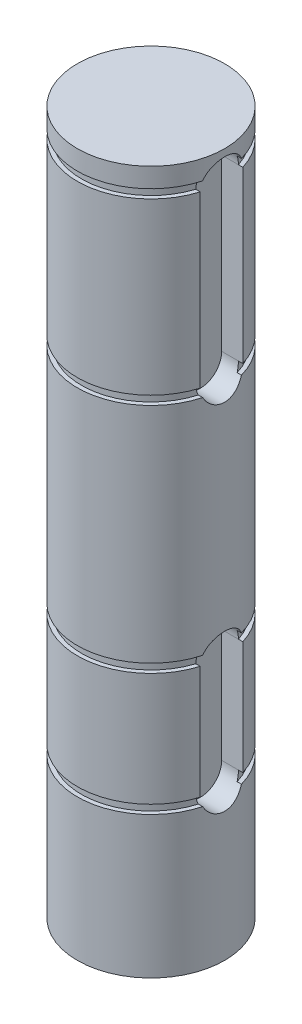
from build123d import *

# Parameters (mm, degrees)
SKETCH1_R           = 8.255
BOSS_EXTRUDE1_DEPTH = 78.7908
SKETCH3_W           = 28.144543877
SKETCH3_H           = 0.9906
SKETCH4_W           = 12.873525148
SKETCH4_H           = 0.9906
SKETCH5_W           = 18.510298187
SKETCH5_H           = 0.9906
SKETCH6_W           = 13.338836726
SKETCH6_H           = 0.9906
CUT_EXTRUDE2_DEPTH  = 2.7432
CUT_EXTRUDE3_DEPTH  = 2.7432


with BuildPart() as part:
    # Sketch1 → Boss-Extrude1 (new body)
    with BuildSketch(Plane(origin=(0, 0, 0), x_dir=(1, 0, 0), z_dir=(0, 1, 0))):
        Circle(SKETCH1_R)
    extrude(amount=BOSS_EXTRUDE1_DEPTH)

    # Sketch3 → Cut-Revolve1 (revolve, cut)
    with BuildSketch(Plane(origin=(0, 0, 0), x_dir=(0, 0, -1), z_dir=(1, 0, 0))):
        with Locations((-21.857371939, 16.3703)):
            Rectangle(SKETCH3_W, SKETCH3_H)
    revolve(axis=Axis((0, 29.927318778, 0), (0, -1, 0)), mode=Mode.SUBTRACT)

    # Sketch4 → Cut-Revolve2 (revolve, cut)
    with BuildSketch(Plane(origin=(0, 0, 0), x_dir=(0, 0, -1), z_dir=(1, 0, 0))):
        with Locations((-14.221862574, 30.0609)):
            Rectangle(SKETCH4_W, SKETCH4_H)
    revolve(axis=Axis((0, 33.790657772, 0), (0, -1, 0)), mode=Mode.SUBTRACT)

    # Sketch5 → Cut-Revolve3 (revolve, cut)
    with BuildSketch(Plane(origin=(0, 0, 0), x_dir=(0, 0, -1), z_dir=(1, 0, 0))):
        with Locations((-17.040249094, 56.0705)):
            Rectangle(SKETCH5_W, SKETCH5_H)
    revolve(axis=Axis((0, 60.607773061, 0), (0, -1, 0)), mode=Mode.SUBTRACT)

    # Sketch6 → Cut-Revolve4 (revolve, cut)
    with BuildSketch(Plane(origin=(0, 0, 0), x_dir=(0, 0, -1), z_dir=(1, 0, 0))):
        with Locations((-14.454518363, 76.1111)):
            Rectangle(SKETCH6_W, SKETCH6_H)
    revolve(axis=Axis((0, 77.155375287, 0), (0, -1, 0)), mode=Mode.SUBTRACT)

    # Sketch7 → Cut-Extrude2 (cut)
    with BuildSketch(Plane(origin=(8.2804, 0, 0), x_dir=(0, 0, -1), z_dir=(1, 0, 0))):
        with BuildLine():
            Line((2.3876, 75.6158), (2.3876, 56.5658))
            ThreePointArc((2.3876, 56.5658), (0, 54.1782), (-2.3876, 56.5658))
            Line((-2.3876, 56.5658), (-2.3876, 75.6158))
            ThreePointArc((-2.3876, 75.6158), (0, 78.0034), (2.3876, 75.6158))
        make_face()
    extrude(amount=-CUT_EXTRUDE2_DEPTH, mode=Mode.SUBTRACT)

    # Sketch8 → Cut-Extrude3 (cut)
    with BuildSketch(Plane(origin=(8.2804, 0, 0), x_dir=(0, 0, -1), z_dir=(1, 0, 0))):
        with BuildLine():
            Line((2.3876, 29.5656), (2.3876, 16.8656))
            ThreePointArc((2.3876, 16.8656), (0, 14.478), (-2.3876, 16.8656))
            Line((-2.3876, 16.8656), (-2.3876, 29.5656))
            ThreePointArc((-2.3876, 29.5656), (0, 31.9532), (2.3876, 29.5656))
        make_face()
    extrude(amount=-CUT_EXTRUDE3_DEPTH, mode=Mode.SUBTRACT)


solid = part.part
